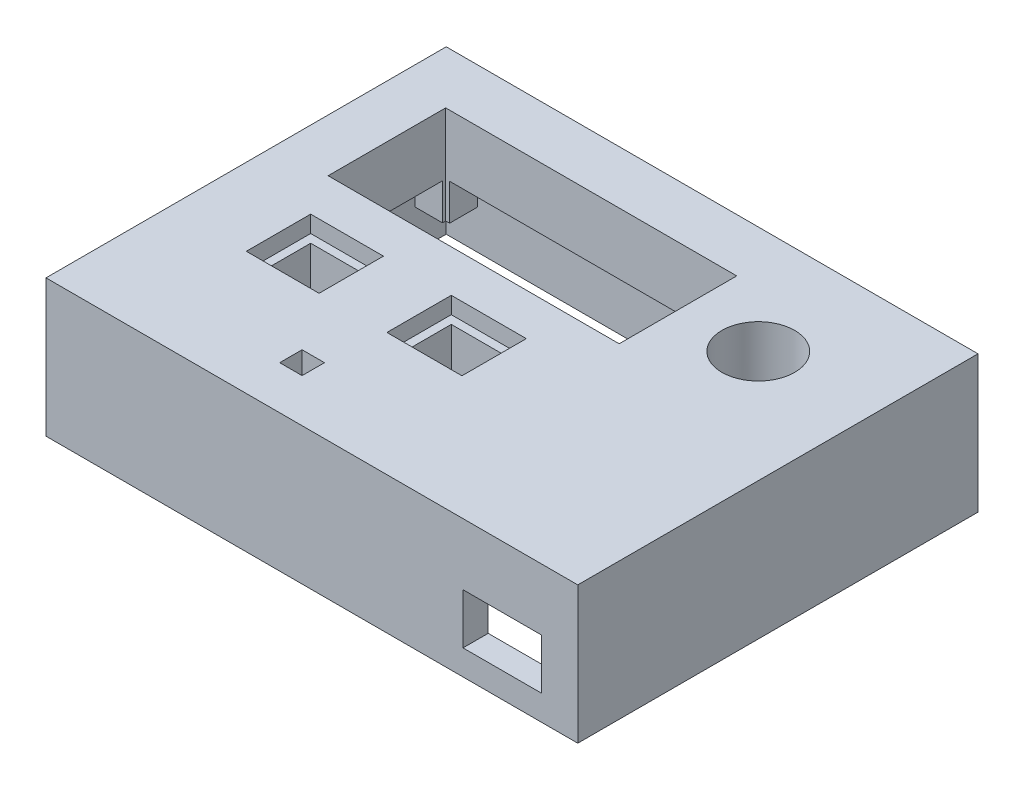
from build123d import *

# Parameters (mm, degrees)
SKETCH1_W             = 13
SKETCH1_H             = 11.5
SKETCH1_W_2           = 13.406613497
SKETCH1_W_3           = 52
SKETCH1_H_2           = 21
SKETCH1_R             = 6.5
BOSS_EXTRUDE1_DEPTH   = 3
SKETCH2_W             = 95
SKETCH2_H             = 71.500049505
BOSS_EXTRUDE2_DEPTH   = 21.5
SKETCH3_R             = 1.25
SKETCH3_W             = 7.478374846
SKETCH3_H             = 5.979454016
SKETCH3_W_2           = 5.973627986
SKETCH3_H_2           = 6.528755861
BOSS_EXTRUDE3_DEPTH   = 14.5
CUT_EXTRUDE1_REACH    = 73.5
SKETCH4_W             = 14
SKETCH4_H             = 9
SKETCH5_R             = 8.5
SKETCH5_R_2           = 6.5
SKETCH5_W             = 56
SKETCH5_H             = 25
SKETCH5_W_2           = 52
SKETCH5_H_2           = 21
BOSS_EXTRUDE4_DEPTH   = 8
SKETCH7_W             = 6
SKETCH7_H             = 6
SKETCH7_W_2           = 4
SKETCH7_H_2           = 4
BOSS_EXTRUDE5_DEPTH   = 13
SKETCH8_W             = 10
SKETCH8_H             = 8.5
BOSS_EXTRUDE6_DEPTH   = 9
SKETCH8_W_2           = 13.406613497
SKETCH8_H_2           = 11.5
SKETCH8_W_3           = 10.406613497
BOSS_EXTRUDE6_2_DEPTH = 9
SKETCH9_W             = 17.406613497
SKETCH9_H             = 15.5
SKETCH9_W_2           = 13.406613497
SKETCH9_H_2           = 11.5
SKETCH9_W_3           = 17
SKETCH9_W_4           = 13
BOSS_EXTRUDE7_DEPTH   = 3
CUT_EXTRUDE2_DEPTH    = 5


with BuildPart() as part:
    # Sketch1 → Boss-Extrude1 (new body)
    with BuildSketch(Plane(origin=(0, 0, 0), x_dir=(1, 0, 0), z_dir=(0, 1, 0))):
        Polygon((48, 35.75), (46, 35.75), (45, 35.75), (-47, 35.75), (-47, 33.75), (-47, -33.75), (-47, -35.750049505), (45, -35.750049505), (46, -35.750049505), (48, -35.750049505), align=None)
        Polygon((-8, -29), (-11, -29), (-14, -29), (-14, -23), (-8, -23), align=None, mode=Mode.SUBTRACT)
        with Locations((-26.716961343, -8)):
            Rectangle(SKETCH1_W, SKETCH1_H, mode=Mode.SUBTRACT)
        with Locations((-1.396693251, -8)):
            Rectangle(SKETCH1_W_2, SKETCH1_H, mode=Mode.SUBTRACT)
        with Locations((-11.6, 15.75)):
            Rectangle(SKETCH1_W_3, SKETCH1_H_2, mode=Mode.SUBTRACT)
        with Locations((28, 16.5)):
            Circle(SKETCH1_R, mode=Mode.SUBTRACT)
    extrude(amount=BOSS_EXTRUDE1_DEPTH)

    # Sketch2 → Boss-Extrude2 (add)
    with BuildSketch(Plane.XZ):
        with Locations((0.5, 2.4752e-05)):
            Rectangle(SKETCH2_W, SKETCH2_H)
        Polygon((41.5, -31.25), (40.5, -31.25), (-42.5, -31.25), (-42.5, 31.25), (40.5, 31.25), (41.5, 31.25), (43.5, 31.25), (43.5, -31.25), align=None, mode=Mode.SUBTRACT)
    extrude(amount=BOSS_EXTRUDE2_DEPTH)

    # Sketch3 → Boss-Extrude3 (add)
    with BuildSketch(Plane.XZ):
        Polygon((-38.8, -25.675777927), (-42.5, -25.675777927), (-42.5, -31.25), (-36.902935229, -31.25), (-36.902935229, -27.93), (-36.902935229, -26.25), (-37.6, -26.25), (-37.6, -25.675777927), align=None)
        with Locations((-38.8, -27.93)):
            Circle(SKETCH3_R, mode=Mode.SUBTRACT)
        with Locations((39.760812577, -28.260272992)):
            Rectangle(SKETCH3_W, SKETCH3_H)
        with Locations((39.43, -27.68)):
            Circle(SKETCH3_R, mode=Mode.SUBTRACT)
        with Locations((18.554223867, 27.98562207)):
            Rectangle(SKETCH3_W_2, SKETCH3_H_2)
        with Locations((18.47, 27.69)):
            Circle(SKETCH3_R, mode=Mode.SUBTRACT)
    extrude(amount=BOSS_EXTRUDE3_DEPTH)

    # Sketch4 → Cut-Extrude1 (cut, up to next)
    with BuildSketch(Plane.XY.offset(35.750049505), mode=Mode.PRIVATE) as cut_extrude1_sk1:
        with Locations((34.5, -12.5)):
            Rectangle(SKETCH4_W, SKETCH4_H)
    cut_extrude1_tool1 = extrude(cut_extrude1_sk1.sketch, amount=-CUT_EXTRUDE1_REACH, mode=Mode.PRIVATE) & part.part
    add(cut_extrude1_tool1.solids().sort_by_distance((34.5, -12.5, 35.75005))[0], mode=Mode.SUBTRACT)

    # Sketch5 → Boss-Extrude4 (add)
    with BuildSketch(Plane.XZ):
        with Locations((28, -16.5)):
            Circle(SKETCH5_R)
        with Locations((28, -16.5)):
            Circle(SKETCH5_R_2, mode=Mode.SUBTRACT)
        with Locations((-11.6, -15.75)):
            Rectangle(SKETCH5_W, SKETCH5_H)
        with Locations((-11.6, -15.75)):
            Rectangle(SKETCH5_W_2, SKETCH5_H_2, mode=Mode.SUBTRACT)
    extrude(amount=BOSS_EXTRUDE4_DEPTH)

    # Sketch7 → Boss-Extrude5 (add)
    with BuildSketch(Plane(origin=(0, 3, 0), x_dir=(1, 0, 0), z_dir=(0, 1, 0))):
        with Locations((-11, -26)):
            Rectangle(SKETCH7_W, SKETCH7_H)
        with Locations((-11, -26)):
            Rectangle(SKETCH7_W_2, SKETCH7_H_2, mode=Mode.SUBTRACT)
    extrude(amount=-BOSS_EXTRUDE5_DEPTH)



with BuildPart() as body_2:
    # Sketch8 → Boss-Extrude6 (new body)
    with BuildSketch(Plane.XZ):
        Polygon((-33.216961343, 12.25), (-33.216961343, 2.25), (-20.216961343, 2.25), (-20.216961343, 12.25), (-20.216961343, 13.75), (-33.216961343, 13.75), align=None)
        with Locations((-26.716961343, 8)):
            Rectangle(SKETCH8_W, SKETCH8_H, mode=Mode.SUBTRACT)
    extrude(amount=BOSS_EXTRUDE6_DEPTH)


with BuildPart() as body_3:
    # Sketch8 → Boss-Extrude6 2 (new body)
    with BuildSketch(Plane.XZ):
        with Locations((-1.396693251, 8)):
            Rectangle(SKETCH8_W_2, SKETCH8_H_2)
        with Locations((-1.396693252, 8)):
            Rectangle(SKETCH8_W_3, SKETCH8_H, mode=Mode.SUBTRACT)
    extrude(amount=BOSS_EXTRUDE6_2_DEPTH)


with BuildPart() as part_1:
    add(part.part)

    add(body_2.part)  # Boss-Extrude7 merges body 2

    add(body_3.part)  # Boss-Extrude7 merges body 3
    # Sketch9 → Boss-Extrude7 (add)
    with BuildSketch(Plane.XZ):
        with Locations((-1.396693252, 8)):
            Rectangle(SKETCH9_W, SKETCH9_H)
        with Locations((-1.396693251, 8)):
            Rectangle(SKETCH9_W_2, SKETCH9_H_2, mode=Mode.SUBTRACT)
        with Locations((-26.716961343, 8)):
            Rectangle(SKETCH9_W_3, SKETCH9_H)
        with Locations((-26.716961343, 8)):
            Rectangle(SKETCH9_W_4, SKETCH9_H_2, mode=Mode.SUBTRACT)
    extrude(amount=BOSS_EXTRUDE7_DEPTH)

    # Sketch10 → Cut-Extrude2 (cut)
    with BuildSketch(Plane.XZ.offset(8)):
        with BuildLine():
            Line((-39.6, -28.25), (-39.6, -26.969531364))
            ThreePointArc((-39.6, -26.969531364), (-38.127998072, -26.876001229), (-37.591654023, -28.25))
            Line((-37.591654023, -28.25), (-39.6, -28.25))
        make_face()
    extrude(amount=-CUT_EXTRUDE2_DEPTH, mode=Mode.SUBTRACT)


solid = part_1.part
